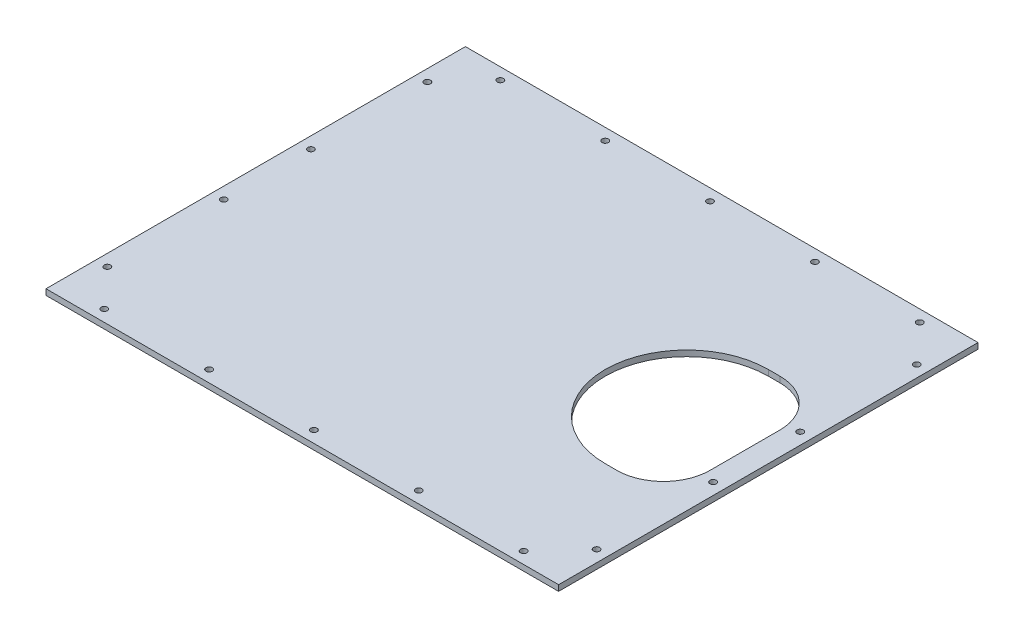
from build123d import *

# Parameters (mm, degrees)
ESQUISSE1_W        = 440
ESQUISSE1_H        = 360
ESQUISSE1_R        = 2.7
BOSS_EXTRU_1_DEPTH = 5
CONG_1_R           = 40


with BuildPart() as part:
    # Esquisse1 → Boss.-Extru.1 (new body)
    with BuildSketch(Plane(origin=(0, 0, 0), x_dir=(1, 0, 0), z_dir=(0, 1, 0))):
        with Locations((220, 180)):
            Rectangle(ESQUISSE1_W, ESQUISSE1_H)
        with Locations((40, 350)):
            Circle(ESQUISSE1_R, mode=Mode.SUBTRACT)
        with Locations((130, 350)):
            Circle(ESQUISSE1_R, mode=Mode.SUBTRACT)
        with Locations((220, 350)):
            Circle(ESQUISSE1_R, mode=Mode.SUBTRACT)
        with Locations((310, 350)):
            Circle(ESQUISSE1_R, mode=Mode.SUBTRACT)
        with Locations((400, 350)):
            Circle(ESQUISSE1_R, mode=Mode.SUBTRACT)
        with Locations((400, 10)):
            Circle(ESQUISSE1_R, mode=Mode.SUBTRACT)
        with Locations((310, 10)):
            Circle(ESQUISSE1_R, mode=Mode.SUBTRACT)
        with Locations((220, 10)):
            Circle(ESQUISSE1_R, mode=Mode.SUBTRACT)
        with Locations((130, 10)):
            Circle(ESQUISSE1_R, mode=Mode.SUBTRACT)
        with Locations((40, 10)):
            Circle(ESQUISSE1_R, mode=Mode.SUBTRACT)
        with Locations((10, 217.36725867)):
            Circle(ESQUISSE1_R, mode=Mode.SUBTRACT)
        with Locations((10, 317.36725867)):
            Circle(ESQUISSE1_R, mode=Mode.SUBTRACT)
        with Locations((10, 42.63274133)):
            Circle(ESQUISSE1_R, mode=Mode.SUBTRACT)
        with Locations((10, 142.63274133)):
            Circle(ESQUISSE1_R, mode=Mode.SUBTRACT)
        with Locations((430, 142.63274133)):
            Circle(ESQUISSE1_R, mode=Mode.SUBTRACT)
        with Locations((430, 42.63274133)):
            Circle(ESQUISSE1_R, mode=Mode.SUBTRACT)
        with Locations((430, 317.36725867)):
            Circle(ESQUISSE1_R, mode=Mode.SUBTRACT)
        with Locations((430, 217.36725867)):
            Circle(ESQUISSE1_R, mode=Mode.SUBTRACT)
        with BuildLine():
            Line((370, 250), (420, 250))
            Line((420, 250), (420, 110))
            Line((420, 110), (370, 110))
            ThreePointArc((370, 110), (300, 180), (370, 250))
        make_face(mode=Mode.SUBTRACT)
    extrude(amount=BOSS_EXTRU_1_DEPTH)

    # Congé1
    cong_1_edges = [part.edges().sort_by_distance(p)[0] for p in [
        (420, 2.5, -110),
        (420, 2.5, -250),
    ]]
    fillet(cong_1_edges, radius=CONG_1_R)


solid = part.part
